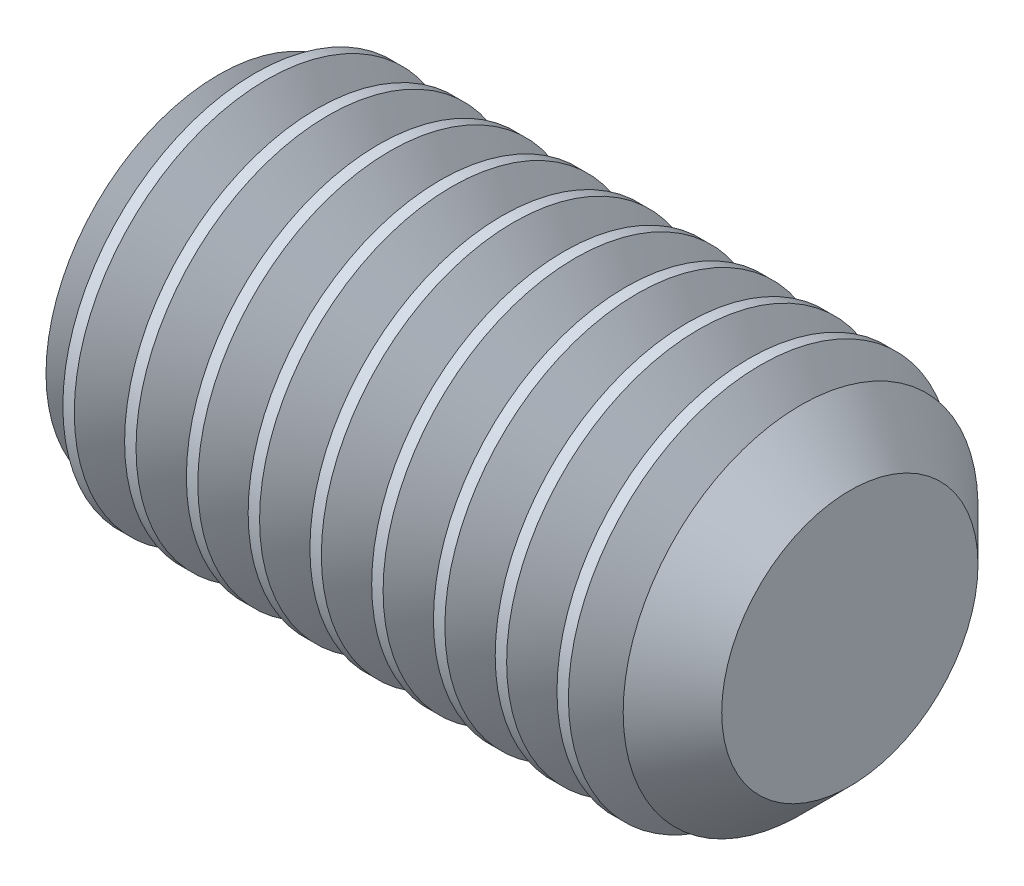
from build123d import *

# Parameters (mm, degrees)
HEX_2_DEPTH     = 2.1
THDSCHPAT_COUNT = 10
THDSCHPAT_PITCH = 0.482005923


with BuildPart() as part:
    # BodySke → BaseBody (revolve)
    with BuildSketch(Plane.XY):
        Polygon((0, 0), (0, 1.2195), (0.161946751, 1.5), (4.5, 1.5), (5, 1), (5, 0), align=None)
    revolve(axis=Axis((-12.7, 0, 0), (1, 0, 0)))

    # Sketch2 → Hex 2 (cut)
    with BuildSketch(Plane.ZY):
        Polygon((0.433012702, 0.75), (-0.433012702, 0.75), (-0.866025404, 0), (-0.433012702, -0.75), (0.433012702, -0.75), (0.866025404, 0), align=None)
    extrude(amount=-HEX_2_DEPTH, mode=Mode.SUBTRACT)

    # ThdSchSke → ThreadSchematic (revolve, cut)
    with BuildSketch(Plane.XY):
        Polygon((0.161946751, -1.2195), (-0.034461464, -1.5), (-0.034461464, -1.875), (0.358354965, -1.875), (0.358354965, -1.5), align=None)
    threadschematic = revolve(axis=Axis((-3.175, 0, 0), (1, 0, 0)), mode=Mode.SUBTRACT)

    # ThdSchPat: ThreadSchematic ×10
    with Locations(*[(i * THDSCHPAT_PITCH, 0, 0) for i in range(1, THDSCHPAT_COUNT)]):
        add(threadschematic, mode=Mode.SUBTRACT)


solid = part.part
